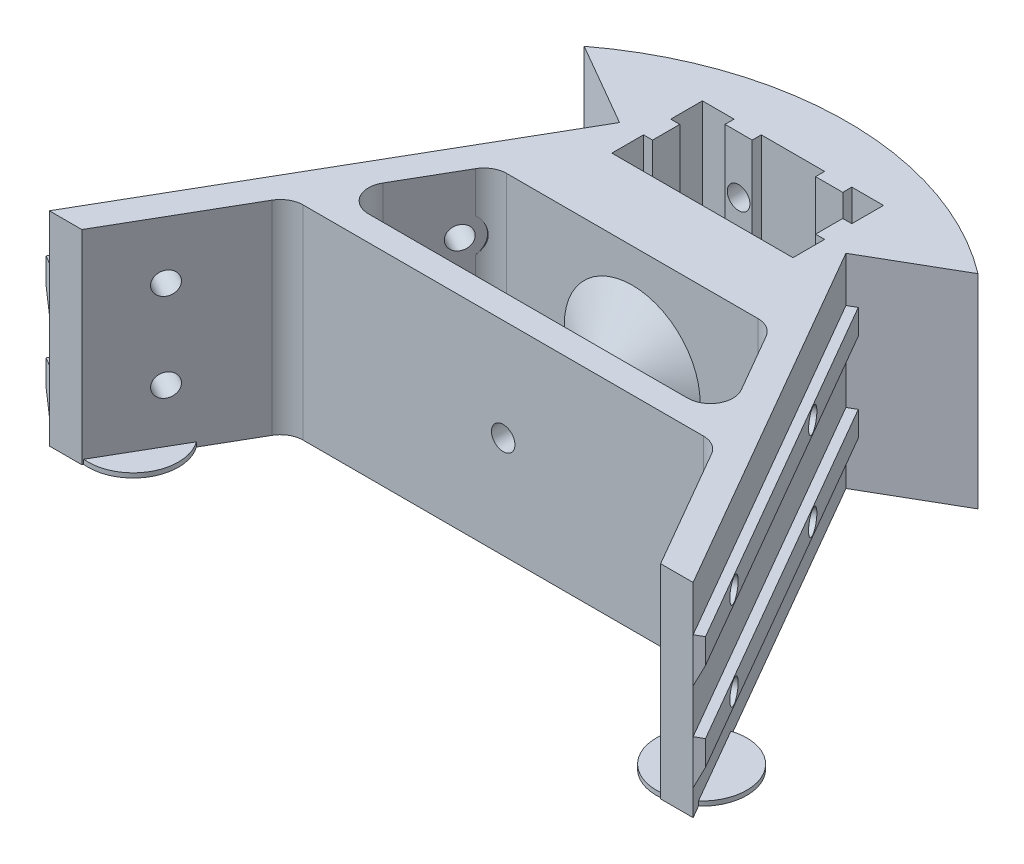
from build123d import *

# Parameters (mm, degrees)
BOSS_EXTRUDE1_DEPTH = 45
SKETCH3_W           = 92.200496998
SKETCH3_H           = 5.5
BOSS_EXTRUDE2_DEPTH = 2
SKETCH4_R           = 2.5
CUT_EXTRUDE2_DEPTH  = 8.222605
SKETCH8_R           = 4.5
CUT_EXTRUDE7_DEPTH  = 0.386255
CUT_EXTRUDE3_START  = -13.60831
SKETCH5_R           = 2.5
CUT_EXTRUDE3_DEPTH  = 13.60831
CUT_EXTRUDE5_START  = -14
SKETCH6_R           = 4.25
CUT_EXTRUDE5_DEPTH  = 1.7
SKETCH10_R          = 2.6
CUT_EXTRUDE8_DEPTH  = 32
SKETCH11_R          = 10
BOSS_EXTRUDE3_DEPTH = 1
BOSS_EXTRUDE4_DEPTH = 0.7
LPATTERN1_COUNT     = 46
LPATTERN1_PITCH     = 2
BOSS_EXTRUDE5_DEPTH = 0.7
LPATTERN2_COUNT     = 46
LPATTERN2_PITCH     = 2


with BuildPart() as part:
    # Sketch1 → Boss-Extrude1 (new body)
    with BuildSketch(Plane(origin=(0, 0, 0), x_dir=(1, 0, 0), z_dir=(0, 1, 0))):
        with BuildLine():
            Line((67.073634163, -66.174942219), (25, 6.698729811))
            Line((25, 6.698729811), (43.49555567, 17.377143855))
            ThreePointArc((43.49555567, 17.377143855), (0, 32), (-43.49555567, 17.377143855))
            Line((-43.49555567, 17.377143855), (-25, 6.698729811))
            Line((-25, 6.698729811), (-67.073634163, -66.174942219))
            Line((-67.073634163, -66.174942219), (-71.100248499, -73.149242831))
            Line((-71.100248499, -73.149242831), (-63.915003714, -73.149242831))
            Line((-63.915003714, -73.149242831), (-48.529056191, -46.5))
            ThreePointArc((-48.529056191, -46.5), (-46.698929172, -44.669872981), (-44.198929172, -44))
            Line((-44.198929172, -44), (44.198929172, -44))
            ThreePointArc((44.198929172, -44), (46.698929172, -44.669872981), (48.529056191, -46.5))
            Line((48.529056191, -46.5), (63.915003714, -73.149242831))
            Line((63.915003714, -73.149242831), (71.100248499, -73.149242831))
            Line((71.100248499, -73.149242831), (67.073634163, -66.174942219))
        make_face()
        Polygon((-20, 20), (-13, 20), (-13, 18), (-7, 18), (-7, 20), (7, 20), (7, 18), (13, 18), (13, 20), (20, 20), (20, 13), (18, 13), (18, 7), (20, 7), (20, 0), (-20, 0), (-20, 7), (-18, 7), (-18, 13), (-20, 13), align=None, mode=Mode.SUBTRACT)
        with BuildLine():
            Line((-27.744446501, -15.5), (27.744446501, -15.5))
            ThreePointArc((27.744446501, -15.5), (30.244446501, -16.169872981), (32.074573519, -18))
            Line((32.074573519, -18), (39.580127019, -31))
            ThreePointArc((39.580127019, -31), (39.580127019, -36), (35.25, -38.5))
            Line((35.25, -38.5), (-35.25, -38.5))
            ThreePointArc((-35.25, -38.5), (-39.580127019, -36), (-39.580127019, -31))
            Line((-39.580127019, -31), (-32.074573519, -18))
            ThreePointArc((-32.074573519, -18), (-30.244446501, -16.169872981), (-27.744446501, -15.5))
        make_face(mode=Mode.SUBTRACT)
    extrude(amount=BOSS_EXTRUDE1_DEPTH)

    # Sketch3 → Boss-Extrude2 (add)
    with BuildSketch(Plane(origin=(21.650635095, 0, -12.5), x_dir=(-0.5, 0, -0.866025404), z_dir=(0.866025404, 0, -0.5))):
        with Locations((-52.79897831, 32.25)):
            Rectangle(SKETCH3_W, SKETCH3_H)
        with Locations((-52.79897831, 12.75)):
            Rectangle(SKETCH3_W, SKETCH3_H)
    boss_extrude2 = extrude(amount=BOSS_EXTRUDE2_DEPTH)

    # Sketch4 → Cut-Extrude2 (cut)
    with BuildSketch(Plane(origin=(23.382685902, 0, -13.5), x_dir=(-0.5, 0, -0.866025404), z_dir=(0.866025404, 0, -0.5))):
        with Locations((-34.198729811, 32.25)):
            Circle(SKETCH4_R)
        with Locations((-34.198729811, 12.75)):
            Circle(SKETCH4_R)
        with Locations((-81.698729811, 12.75)):
            Circle(SKETCH4_R)
        with Locations((-81.698729811, 32.25)):
            Circle(SKETCH4_R)
    cut_extrude2 = extrude(amount=-CUT_EXTRUDE2_DEPTH, mode=Mode.SUBTRACT)

    # Sketch8 → Cut-Extrude7 (cut)
    with BuildSketch(Plane(origin=(16.261701506, 0, -9.388697742), x_dir=(0.5, 0, 0.866025404), z_dir=(-0.866025404, 0, 0.5))):
        with Locations((34.198729811, 32.25)):
            Circle(SKETCH8_R)
        with Locations((34.198729811, 12.75)):
            Circle(SKETCH8_R)
    cut_extrude7 = extrude(amount=CUT_EXTRUDE7_DEPTH, mode=Mode.SUBTRACT)

    # Sketch5 → Cut-Extrude3 (cut)
    with BuildSketch(Plane.XY.offset(-18).offset(CUT_EXTRUDE3_START)):
        with Locations((10, 32.5)):
            Circle(SKETCH5_R)
        with Locations((10, 12.5)):
            Circle(SKETCH5_R)
    cut_extrude3 = extrude(amount=CUT_EXTRUDE3_DEPTH, mode=Mode.SUBTRACT)

    # Sketch6 → Cut-Extrude5 (cut)
    with BuildSketch(Plane.XY.offset(-18).offset(CUT_EXTRUDE5_START)):
        with Locations((10, 32.5)):
            Circle(SKETCH6_R)
        with Locations((10, 12.5)):
            Circle(SKETCH6_R)
    cut_extrude5 = extrude(amount=CUT_EXTRUDE5_DEPTH, mode=Mode.SUBTRACT)

    # Mirror1: Boss-Extrude2, Cut-Extrude2, Cut-Extrude7, Cut-Extrude3, Cut-Extrude5 across plane
    add(boss_extrude2.mirror(Plane(origin=(0, 0, 0), x_dir=(0, 0, 1), z_dir=(1, 0, 0))))
    add(cut_extrude2.mirror(Plane(origin=(0, 0, 0), x_dir=(0, 0, 1), z_dir=(1, 0, 0))), mode=Mode.SUBTRACT)
    add(cut_extrude7.mirror(Plane(origin=(0, 0, 0), x_dir=(0, 0, 1), z_dir=(1, 0, 0))), mode=Mode.SUBTRACT)
    add(cut_extrude3.mirror(Plane(origin=(0, 0, 0), x_dir=(0, 0, 1), z_dir=(1, 0, 0))), mode=Mode.SUBTRACT)
    add(cut_extrude5.mirror(Plane(origin=(0, 0, 0), x_dir=(0, 0, 1), z_dir=(1, 0, 0))), mode=Mode.SUBTRACT)

    # Sketch9 → Revolve1 (revolve)
    with BuildSketch(Plane(origin=(0, 0, 0), x_dir=(0, 0, -1), z_dir=(1, 0, 0))):
        Polygon((-31.1, 26.1), (-31.1, 22.5), (-38.5, 22.5), (-38.5, 37.5), align=None)
        Polygon((-22.9, 26.1), (-15.5, 37.5), (-15.5, 22.5), (-22.9, 22.5), align=None)
    revolve(axis=Axis((0, 22.5, 15.5), (0, 0, 1)))

    # Sketch10 → Cut-Extrude8 (cut)
    with BuildSketch(Plane.XY.offset(44)):
        with Locations((0, 22.5)):
            Circle(SKETCH10_R)
    extrude(amount=-CUT_EXTRUDE8_DEPTH, mode=Mode.SUBTRACT)

    # Sketch11 → Boss-Extrude3 (add)
    with BuildSketch(Plane(origin=(0, 0, 0), x_dir=(1, 0, 0), z_dir=(0, 1, 0))):
        with Locations((62.771807108, -62.946563711)):
            Circle(SKETCH11_R)
        with Locations((-62.771807108, -62.946563711)):
            Circle(SKETCH11_R)
    extrude(amount=BOSS_EXTRUDE3_DEPTH)

    # Sketch12 → Boss-Extrude4 (add)
    with BuildSketch(Plane(origin=(49.449613404, 0, 85.649242831), x_dir=(0.866025404, 0, -0.5), z_dir=(0.5, 0, 0.866025404))):
        Polygon((25, 29.5), (27, 29.5), (25, 25.210986159), align=None)
        Polygon((25, 10), (27, 10), (25, 5.710986159), align=None)
    boss_extrude4 = extrude(amount=-BOSS_EXTRUDE4_DEPTH)

    # LPattern1: Boss-Extrude4 ×46
    with Locations(*[Vector(-0.5, 0, -0.866025404) * (i * LPATTERN1_PITCH) for i in range(1, LPATTERN1_COUNT)]):
        add(boss_extrude4)

    # Sketch13 → Boss-Extrude5 (add)
    with BuildSketch(Plane(origin=(-49.449613404, 0, 85.649242831), x_dir=(0.866025404, 0, 0.5), z_dir=(-0.5, 0, 0.866025404))):
        Polygon((-25, 29.5), (-27, 29.5), (-25, 25.210986159), align=None)
        Polygon((-25, 10), (-27, 10), (-25, 5.710986159), align=None)
    boss_extrude5 = extrude(amount=-BOSS_EXTRUDE5_DEPTH)

    # LPattern2: Boss-Extrude5 ×46
    with Locations(*[Vector(0.5, 0, -0.866025404) * (i * LPATTERN2_PITCH) for i in range(1, LPATTERN2_COUNT)]):
        add(boss_extrude5)


solid = part.part
